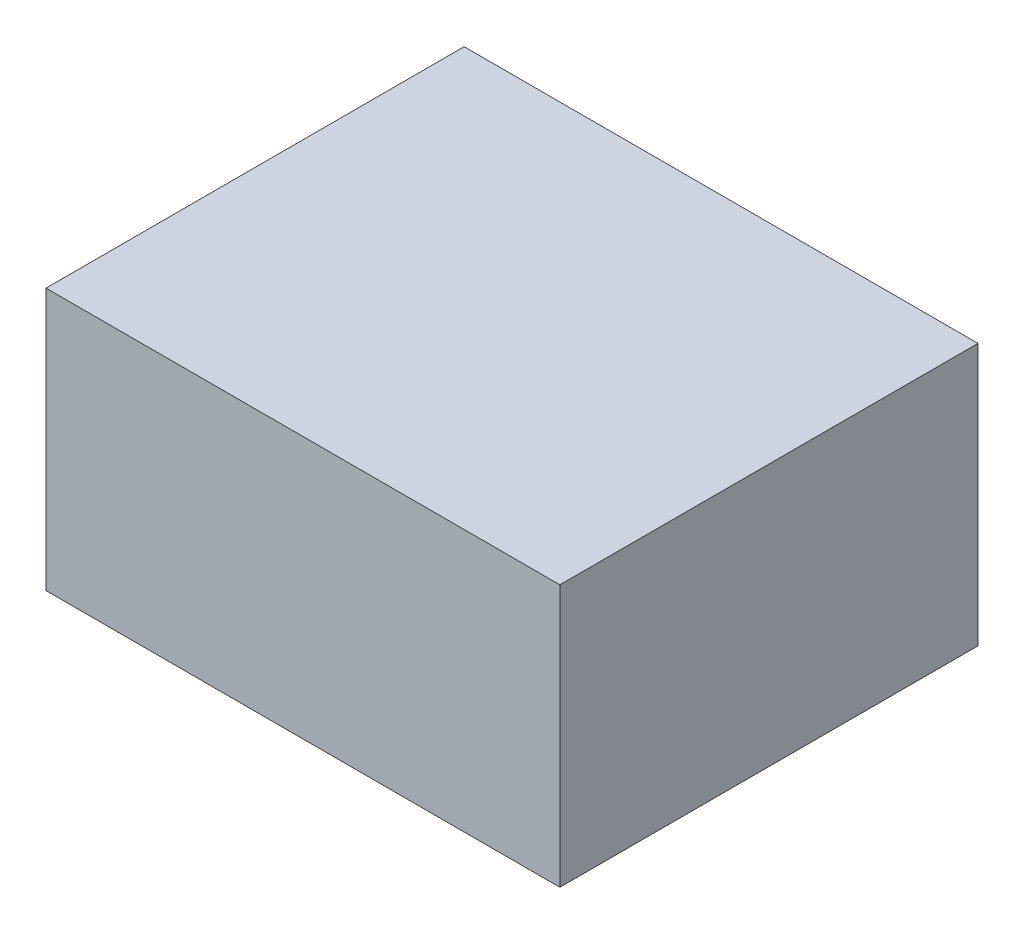
from build123d import *

# Parameters (mm, degrees)
SKETCH1_W           = 51
SKETCH1_H           = 26
BOSS_EXTRUDE1_DEPTH = 41.5


with BuildPart() as part:
    # Sketch1 → Boss-Extrude1 (new body)
    with BuildSketch(Plane.XY):
        Rectangle(SKETCH1_W, SKETCH1_H)
    extrude(amount=BOSS_EXTRUDE1_DEPTH)


solid = part.part
